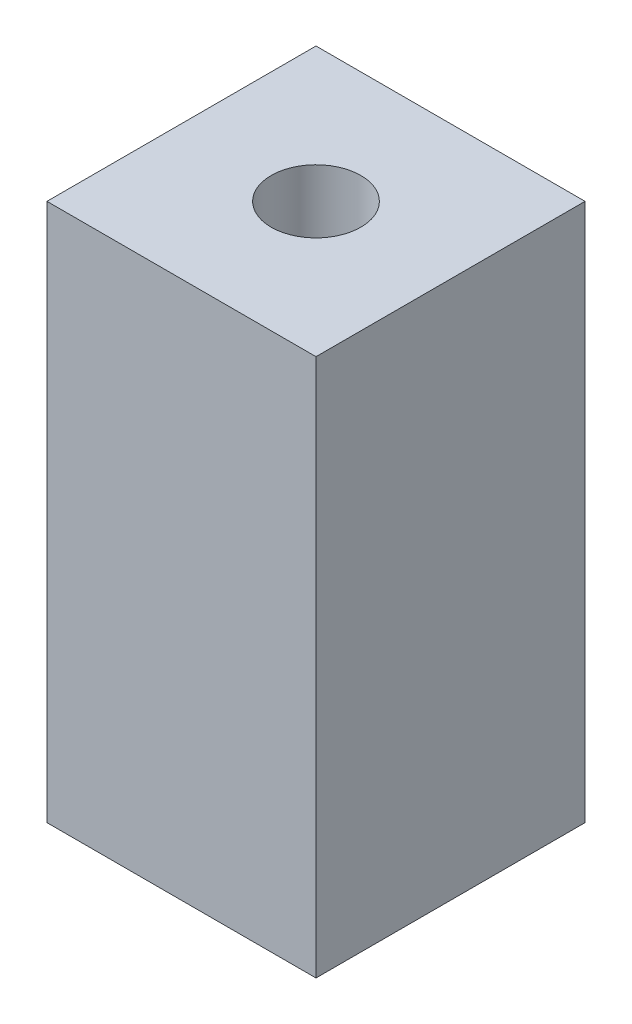
from build123d import *

# Parameters (mm, degrees)
SKETCH1_W           = 19.05
SKETCH1_H           = 19.05
SKETCH1_R           = 3.175
BOSS_EXTRUDE1_DEPTH = 38.1


with BuildPart() as part:
    # Sketch1 → Boss-Extrude1 (new body)
    with BuildSketch(Plane(origin=(0, 0, 0), x_dir=(1, 0, 0), z_dir=(0, 1, 0))):
        Rectangle(SKETCH1_W, SKETCH1_H)
        Circle(SKETCH1_R, mode=Mode.SUBTRACT)
    extrude(amount=BOSS_EXTRUDE1_DEPTH)


solid = part.part
